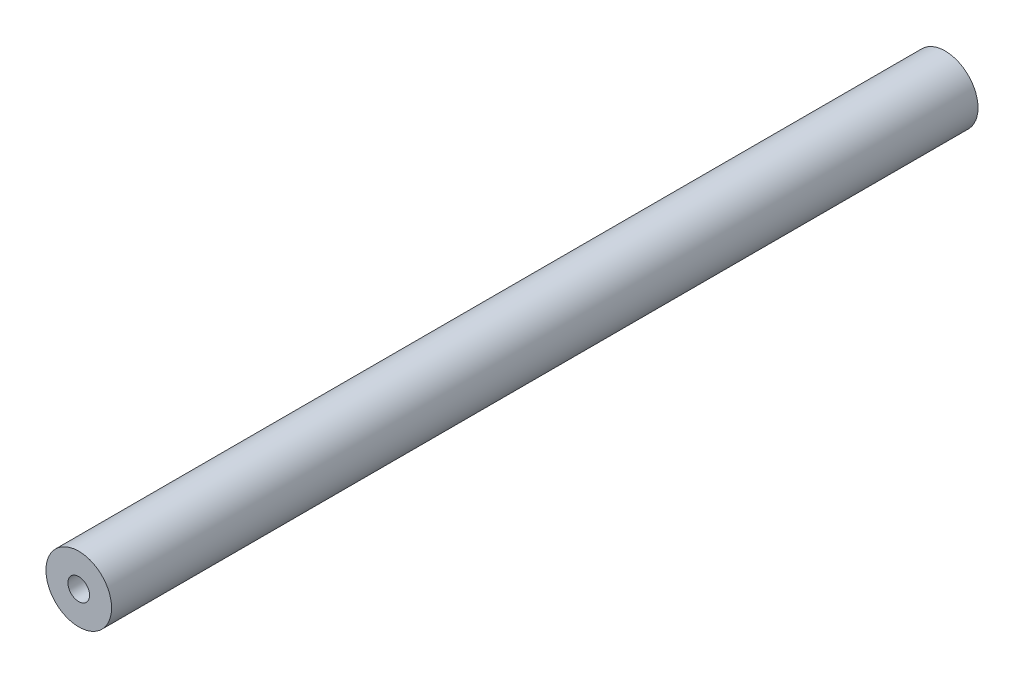
from build123d import *

# Parameters (mm, degrees)
CROQUIS2_R              = 37.875
CROQUIS2_R_2            = 12.5
SALIENTE_EXTRUIR1_DEPTH = 1000


with BuildPart() as part:
    # Croquis2 → Saliente-Extruir1 (new body)
    with BuildSketch(Plane.XY):
        Circle(CROQUIS2_R)
        Circle(CROQUIS2_R_2, mode=Mode.SUBTRACT)
    extrude(amount=SALIENTE_EXTRUIR1_DEPTH)


solid = part.part
